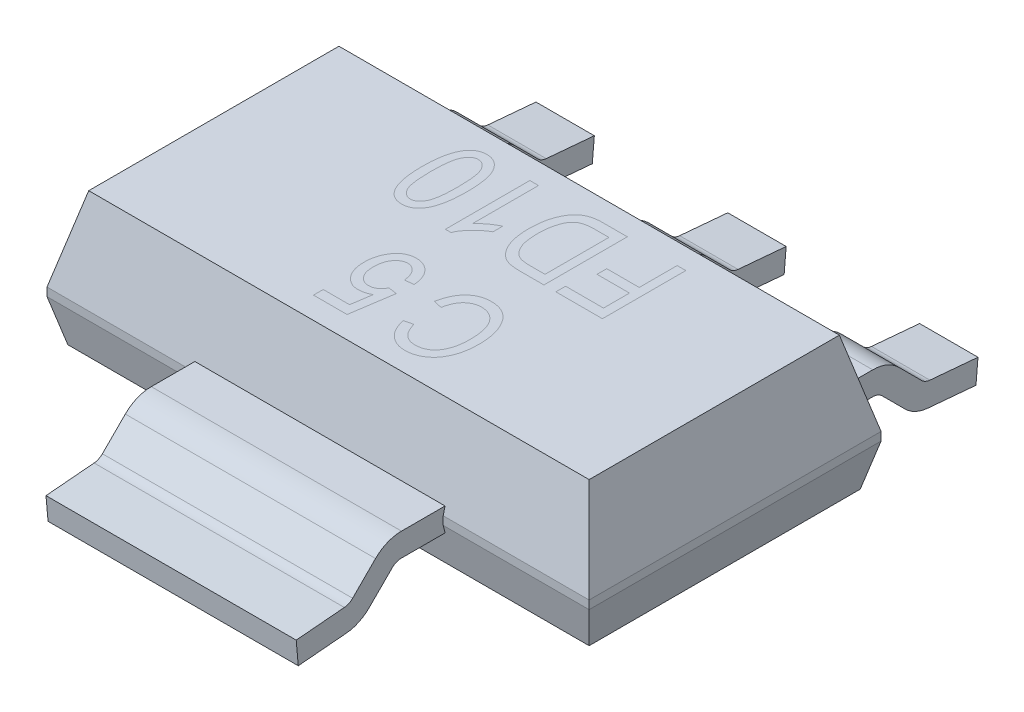
from build123d import *

# Parameters (mm, degrees)
SKETCH1_W             = 6.5
SKETCH1_H             = 3.5
BOSS_EXTRUDE1_DEPTH   = 1.6
CHAMFER1_SIZE         = 1
CHAMFER1_SIZE2        = 0.25
CHAMFER1_PART_2_SIZE  = 1
CHAMFER1_PART_2_SIZE2 = 0.25
CHAMFER1_PART_3_SIZE  = 1
CHAMFER1_PART_3_SIZE2 = 0.25
CHAMFER1_PART_4_SIZE  = 1
CHAMFER1_PART_4_SIZE2 = 0.25
CHAMFER2_SIZE         = 0.125
CHAMFER2_SIZE2        = 0.5
EXTRUDE_THIN1_DEPTH   = 1.5
EXTRUDE_THIN2_DEPTH   = 0.35
LPATTERN1_COUNT       = 3
LPATTERN1_PITCH       = 2.3


with BuildPart() as part:
    # Sketch1 → Boss-Extrude1 (new body)
    with BuildSketch(Plane(origin=(0, 0, 0), x_dir=(1, 0, 0), z_dir=(0, 1, 0))):
        Rectangle(SKETCH1_W, SKETCH1_H)
    extrude(amount=BOSS_EXTRUDE1_DEPTH)

    # Chamfer1
    chamfer1_edges = [part.edges().sort_by_distance(p)[0] for p in [
        (3.25, 1.6, 0),
    ]]
    chamfer1_side = [part.faces().sort_by_distance(p)[0] for p in [
        (3.25, 0.8, 0),
    ]]
    chamfer(chamfer1_edges, length=CHAMFER1_SIZE, length2=CHAMFER1_SIZE2, reference=chamfer1_side[0])

    # Chamfer1 part 2
    chamfer1_part_2_edges = [part.edges().sort_by_distance(p)[0] for p in [
        (0, 1.6, -1.75),
    ]]
    chamfer1_part_2_side = [part.faces().sort_by_distance(p)[0] for p in [
        (0, 0.8, -1.75),
    ]]
    chamfer(chamfer1_part_2_edges, length=CHAMFER1_PART_2_SIZE, length2=CHAMFER1_PART_2_SIZE2, reference=chamfer1_part_2_side[0])

    # Chamfer1 part 3
    chamfer1_part_3_edges = [part.edges().sort_by_distance(p)[0] for p in [
        (-3.25, 1.6, 0),
    ]]
    chamfer1_part_3_side = [part.faces().sort_by_distance(p)[0] for p in [
        (-3.25, 0.8, 0),
    ]]
    chamfer(chamfer1_part_3_edges, length=CHAMFER1_PART_3_SIZE, length2=CHAMFER1_PART_3_SIZE2, reference=chamfer1_part_3_side[0])

    # Chamfer1 part 4
    chamfer1_part_4_edges = [part.edges().sort_by_distance(p)[0] for p in [
        (0, 1.6, 1.75),
    ]]
    chamfer1_part_4_side = [part.faces().sort_by_distance(p)[0] for p in [
        (0, 0.8, 1.75),
    ]]
    chamfer(chamfer1_part_4_edges, length=CHAMFER1_PART_4_SIZE, length2=CHAMFER1_PART_4_SIZE2, reference=chamfer1_part_4_side[0])

    # Chamfer2
    chamfer2_edges = [part.edges().sort_by_distance(p)[0] for p in [
        (0, 0, -1.75),
        (3.25, 0, 0),
        (0, 0, 1.75),
        (-3.25, 0, 0),
    ]]
    chamfer2_side = [part.faces().sort_by_distance(p)[0] for p in [
        (0, 0, 0),
    ]]
    chamfer(chamfer2_edges, length=CHAMFER2_SIZE, length2=CHAMFER2_SIZE2, reference=chamfer2_side[0])

    # Sketch2 → Extrude-Thin1 (add, symmetric)
    with BuildSketch(Plane(origin=(0, 0, 0), x_dir=(0, 0, -1), z_dir=(1, 0, 0))):
        with BuildLine():
            Line((0, 0.69), (-2.25, 0.69))
            ThreePointArc((-2.25, 0.69), (-2.41838071, 0.656506994), (-2.561126984, 0.561126984))
            Line((-2.561126984, 0.561126984), (-2.836055715, 0.286198252))
            ThreePointArc((-2.836055715, 0.286198252), (-2.881573879, 0.254326091), (-2.935247882, 0.239944185))
            Line((-2.935247882, 0.239944185), (-3.512201804, 0.189467258))
            Line((-3.512201804, 0.189467258), (-3.487798196, -0.089467258))
            Line((-3.487798196, -0.089467258), (-2.910844274, -0.03899033))
            ThreePointArc((-2.910844274, -0.03899033), (-2.763240765, 0.000559911), (-2.638065817, 0.088208353))
            Line((-2.638065817, 0.088208353), (-2.363137085, 0.363137085))
            ThreePointArc((-2.363137085, 0.363137085), (-2.311229349, 0.397820725), (-2.25, 0.41))
            Line((-2.25, 0.41), (0, 0.41))
            Line((0, 0.41), (0, 0.69))
        make_face()
    extrude(amount=EXTRUDE_THIN1_DEPTH, both=True)

    # Sketch3 → Extrude-Thin2 (add, symmetric)
    with BuildSketch(Plane(origin=(2.3, 0, 0), x_dir=(0, 0, -1), z_dir=(1, 0, 0))):
        with BuildLine():
            Line((0, 0.41), (2.25, 0.41))
            ThreePointArc((2.25, 0.41), (2.311229349, 0.397820725), (2.363137085, 0.363137085))
            Line((2.363137085, 0.363137085), (2.638065817, 0.088208353))
            ThreePointArc((2.638065817, 0.088208353), (2.763240765, 0.000559911), (2.910844274, -0.03899033))
            Line((2.910844274, -0.03899033), (3.487798196, -0.089467258))
            Line((3.487798196, -0.089467258), (3.512201804, 0.189467258))
            Line((3.512201804, 0.189467258), (2.935247882, 0.239944185))
            ThreePointArc((2.935247882, 0.239944185), (2.881573879, 0.254326091), (2.836055715, 0.286198252))
            Line((2.836055715, 0.286198252), (2.561126984, 0.561126984))
            ThreePointArc((2.561126984, 0.561126984), (2.41838071, 0.656506994), (2.25, 0.69))
            Line((2.25, 0.69), (0, 0.69))
            Line((0, 0.69), (0, 0.41))
        make_face()
    extrude_thin2 = extrude(amount=EXTRUDE_THIN2_DEPTH, both=True)

    # LPattern1: Extrude-Thin2 ×3
    with Locations(*[(-i * LPATTERN1_PITCH, 0, 0) for i in range(1, LPATTERN1_COUNT)]):
        add(extrude_thin2)


solid = part.part
